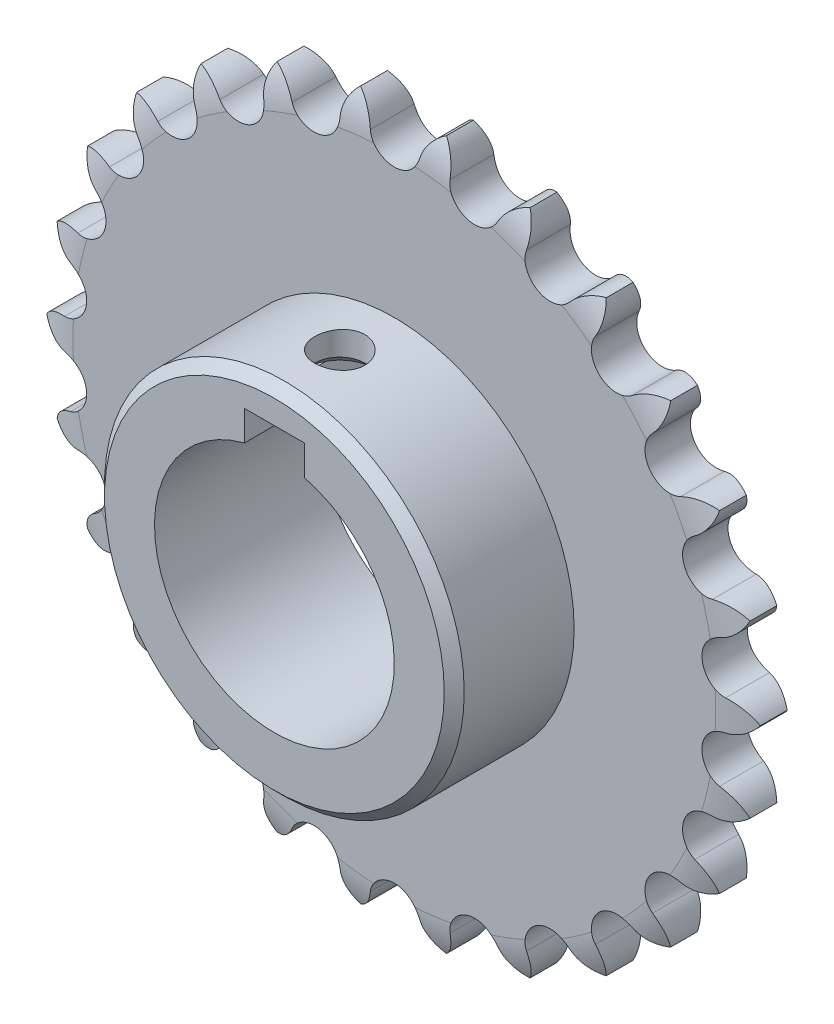
from build123d import *

# Parameters (mm, degrees)
SKETCH2_R           = 19.05
BOSS_EXTRUDE1_DEPTH = 7.2136
SKETCH3_W           = 19.05
SKETCH3_H           = 9.525
SKETCH4_W           = 9.525
SKETCH4_H           = 4.7625
CUT_EXTRUDE1_DEPTH  = 27.2636
CHAMFER1_SIZE       = 1.5875


with BuildPart() as part:
    # Sketch2 → Boss-Extrude1 (new body)
    with BuildSketch(Plane.XY):
        with BuildLine():
            ThreePointArc((3.92972164, 52.414466532), (0, 49.2633), (-3.92972164, 52.414466532))
            ThreePointArc((-3.92972164, 52.414466532), (-4.963717242, 54.655608441), (-6.832202969, 56.268253799))
            ThreePointArc((-6.832202969, 56.268253799), (-8.260462601, 54.255311081), (-8.728071805, 51.831841339))
            ThreePointArc((-8.728071805, 51.831841339), (-11.789479364, 47.831798034), (-16.359133948, 49.950953449))
            ThreePointArc((-16.359133948, 49.950953449), (-17.899423881, 51.879520503), (-20.099546104, 52.998147415))
            ThreePointArc((-20.099546104, 52.998147415), (-21.004574383, 50.701892252), (-20.878621442, 48.236937928))
            ThreePointArc((-20.878621442, 48.236937928), (-22.893797041, 43.620485829), (-27.837812853, 44.584472516))
            ThreePointArc((-27.837812853, 44.584472516), (-29.794881066, 46.088383408), (-32.198776678, 46.647981344))
            ThreePointArc((-32.198776678, 46.647981344), (-32.527976651, 44.201863738), (-31.815781492, 41.838679019))
            ThreePointArc((-31.815781492, 41.838679019), (-32.66761045, 36.87410954), (-37.698659262, 36.626904099))
            ThreePointArc((-37.698659262, 36.626904099), (-39.958768064, 37.618756994), (-42.426731389, 37.586804155))
            ThreePointArc((-42.426731389, 37.586804155), (-42.16097115, 35.132983572), (-40.903923967, 33.008908163))
            ThreePointArc((-40.903923967, 33.008908163), (-40.542901081, 27.984744038), (-45.368596624, 26.540713148))
            ThreePointArc((-45.368596624, 26.540713148), (-47.800396706, 26.962865161), (-50.188998688, 26.341218532))
            ThreePointArc((-50.188998688, 26.341218532), (-49.343723254, 24.022302103), (-47.614879061, 22.260779547))
            ThreePointArc((-47.614879061, 22.260779547), (-46.061985668, 17.469006932), (-50.401876058, 14.912072421))
            ThreePointArc((-50.401876058, 14.912072421), (-52.864040038, 14.739989612), (-55.034463811, 13.564777033))
            ThreePointArc((-55.034463811, 13.564777033), (-53.658797521, 11.515531754), (-51.558630457, 10.218935338))
            ThreePointArc((-51.558630457, 10.218935338), (-48.904115077, 5.93803464), (-52.505981658, 2.416796248))
            ThreePointArc((-52.505981658, 2.416796248), (-54.855417517, 1.660479444), (-56.681525941, 0))
            ThreePointArc((-56.681525941, 0), (-54.855417517, -1.660479444), (-52.505981658, -2.416796248))
            ThreePointArc((-52.505981658, -2.416796248), (-48.904115077, -5.93803464), (-51.558630457, -10.218935338))
            ThreePointArc((-51.558630457, -10.218935338), (-53.658797521, -11.515531754), (-55.034463811, -13.564777033))
            ThreePointArc((-55.034463811, -13.564777033), (-52.864040038, -14.739989612), (-50.401876058, -14.912072421))
            ThreePointArc((-50.401876058, -14.912072421), (-46.061985668, -17.469006932), (-47.614879061, -22.260779547))
            ThreePointArc((-47.614879061, -22.260779547), (-49.343723254, -24.022302103), (-50.188998688, -26.341218532))
            ThreePointArc((-50.188998688, -26.341218532), (-47.800396706, -26.962865161), (-45.368596624, -26.540713148))
            ThreePointArc((-45.368596624, -26.540713148), (-40.542901081, -27.984744038), (-40.903923967, -33.008908163))
            ThreePointArc((-40.903923967, -33.008908163), (-42.16097115, -35.132983572), (-42.426731389, -37.586804155))
            ThreePointArc((-42.426731389, -37.586804155), (-39.958768064, -37.618756994), (-37.698659262, -36.626904099))
            ThreePointArc((-37.698659262, -36.626904099), (-32.66761045, -36.87410954), (-31.815781492, -41.838679019))
            ThreePointArc((-31.815781492, -41.838679019), (-32.527976651, -44.201863738), (-32.198776678, -46.647981344))
            ThreePointArc((-32.198776678, -46.647981344), (-29.794881066, -46.088383408), (-27.837812853, -44.584472516))
            ThreePointArc((-27.837812853, -44.584472516), (-22.893797041, -43.620485829), (-20.878621442, -48.236937928))
            ThreePointArc((-20.878621442, -48.236937928), (-21.004574383, -50.701892252), (-20.099546104, -52.998147415))
            ThreePointArc((-20.099546104, -52.998147415), (-17.899423881, -51.879520503), (-16.359133948, -49.950953449))
            ThreePointArc((-16.359133948, -49.950953449), (-11.789479364, -47.831798034), (-8.728071805, -51.831841339))
            ThreePointArc((-8.728071805, -51.831841339), (-8.260462601, -54.255311081), (-6.832202969, -56.268253799))
            ThreePointArc((-6.832202969, -56.268253799), (-4.963717242, -54.655608441), (-3.92972164, -52.414466532))
            ThreePointArc((-3.92972164, -52.414466532), (0, -49.2633), (3.92972164, -52.414466532))
            ThreePointArc((3.92972164, -52.414466532), (4.963717242, -54.655608441), (6.832202969, -56.268253799))
            ThreePointArc((6.832202969, -56.268253799), (8.260462601, -54.255311081), (8.728071805, -51.831841339))
            ThreePointArc((8.728071805, -51.831841339), (11.789479364, -47.831798034), (16.359133948, -49.950953449))
            ThreePointArc((16.359133948, -49.950953449), (17.899423881, -51.879520503), (20.099546104, -52.998147415))
            ThreePointArc((20.099546104, -52.998147415), (21.004574383, -50.701892252), (20.878621442, -48.236937928))
            ThreePointArc((20.878621442, -48.236937928), (22.893797041, -43.620485829), (27.837812853, -44.584472516))
            ThreePointArc((27.837812853, -44.584472516), (29.794881066, -46.088383408), (32.198776678, -46.647981344))
            ThreePointArc((32.198776678, -46.647981344), (32.527976651, -44.201863738), (31.815781492, -41.838679019))
            ThreePointArc((31.815781492, -41.838679019), (32.66761045, -36.87410954), (37.698659262, -36.626904099))
            ThreePointArc((37.698659262, -36.626904099), (39.958768064, -37.618756994), (42.426731389, -37.586804155))
            ThreePointArc((42.426731389, -37.586804155), (42.16097115, -35.132983572), (40.903923967, -33.008908163))
            ThreePointArc((40.903923967, -33.008908163), (40.542901081, -27.984744038), (45.368596624, -26.540713148))
            ThreePointArc((45.368596624, -26.540713148), (47.800396706, -26.962865161), (50.188998688, -26.341218532))
            ThreePointArc((50.188998688, -26.341218532), (49.343723254, -24.022302103), (47.614879061, -22.260779547))
            ThreePointArc((47.614879061, -22.260779547), (46.061985668, -17.469006932), (50.401876058, -14.912072421))
            ThreePointArc((50.401876058, -14.912072421), (52.864040038, -14.739989612), (55.034463811, -13.564777033))
            ThreePointArc((55.034463811, -13.564777033), (53.658797521, -11.515531754), (51.558630457, -10.218935338))
            ThreePointArc((51.558630457, -10.218935338), (48.904115077, -5.93803464), (52.505981658, -2.416796248))
            ThreePointArc((52.505981658, -2.416796248), (54.855417517, -1.660479444), (56.681525941, 0))
            ThreePointArc((56.681525941, 0), (54.855417517, 1.660479444), (52.505981658, 2.416796248))
            ThreePointArc((52.505981658, 2.416796248), (48.904115077, 5.93803464), (51.558630457, 10.218935338))
            ThreePointArc((51.558630457, 10.218935338), (53.658797521, 11.515531754), (55.034463811, 13.564777033))
            ThreePointArc((55.034463811, 13.564777033), (52.864040038, 14.739989612), (50.401876058, 14.912072421))
            ThreePointArc((50.401876058, 14.912072421), (46.061985668, 17.469006932), (47.614879061, 22.260779547))
            ThreePointArc((47.614879061, 22.260779547), (49.343723254, 24.022302103), (50.188998688, 26.341218532))
            ThreePointArc((50.188998688, 26.341218532), (47.800396706, 26.962865161), (45.368596624, 26.540713148))
            ThreePointArc((45.368596624, 26.540713148), (40.542901081, 27.984744038), (40.903923967, 33.008908163))
            ThreePointArc((40.903923967, 33.008908163), (42.16097115, 35.132983572), (42.426731389, 37.586804155))
            ThreePointArc((42.426731389, 37.586804155), (39.958768064, 37.618756994), (37.698659262, 36.626904099))
            ThreePointArc((37.698659262, 36.626904099), (32.66761045, 36.87410954), (31.815781492, 41.838679019))
            ThreePointArc((31.815781492, 41.838679019), (32.527976651, 44.201863738), (32.198776678, 46.647981344))
            ThreePointArc((32.198776678, 46.647981344), (29.794881066, 46.088383408), (27.837812853, 44.584472516))
            ThreePointArc((27.837812853, 44.584472516), (22.893797041, 43.620485829), (20.878621442, 48.236937928))
            ThreePointArc((20.878621442, 48.236937928), (21.004574383, 50.701892252), (20.099546104, 52.998147415))
            ThreePointArc((20.099546104, 52.998147415), (17.899423881, 51.879520503), (16.359133948, 49.950953449))
            ThreePointArc((16.359133948, 49.950953449), (11.789479364, 47.831798034), (8.728071805, 51.831841339))
            ThreePointArc((8.728071805, 51.831841339), (8.260462601, 54.255311081), (6.832202969, 56.268253799))
            ThreePointArc((6.832202969, 56.268253799), (4.963717242, 54.655608441), (3.92972164, 52.414466532))
        make_face()
        Circle(SKETCH2_R, mode=Mode.SUBTRACT)
    extrude(amount=BOSS_EXTRUDE1_DEPTH)

    # Sketch3 → Revolve1 (revolve)
    with BuildSketch(Plane(origin=(0, 0, 0), x_dir=(0, 0, -1), z_dir=(1, 0, 0))):
        with Locations((-16.7386, 23.8125)):
            Rectangle(SKETCH3_W, SKETCH3_H)
    revolve(axis=Axis((0, 0, 0), (0, 0, 1)))

    # Sketch4 → Cut-Extrude1 (cut, through all)
    with BuildSketch(Plane.XY.offset(26.2636)):
        with Locations((0, 20.826333186)):
            Rectangle(SKETCH4_W, SKETCH4_H)
    extrude(amount=-CUT_EXTRUDE1_DEPTH, mode=Mode.SUBTRACT)

    # Sketch11 → 3/8-16 Tapped Hole2 (revolve, cut)
    with BuildSketch(Plane(origin=(0, 23.207583186, 15.875), x_dir=(0, 0, -1), z_dir=(1, 0, 0))):
        Polygon((0, 0), (0, 9.496665582), (3.96875, 7.112), (3.96875, 1.42875), (5.3975, 0), align=None)
    revolve(axis=Axis((0, 16.857583186, 15.875), (0, 1, 0)), mode=Mode.SUBTRACT)

    # Sketch12 → Cut-Revolve1 (revolve, cut)
    with BuildSketch(Plane(origin=(0, 0, 0), x_dir=(0, 0, -1), z_dir=(1, 0, 0))):
        with BuildLine():
            Line((-7.2136, 50.419), (-7.9756, 50.419))
            Line((-7.9756, 50.419), (-7.9756, 56.896))
            Line((-7.9756, 56.896), (-5.6261, 56.896))
            ThreePointArc((-5.6261, 56.896), (-6.852570348, 53.763558909), (-7.2136, 50.419))
        make_face()
        with BuildLine():
            Line((0, 50.419), (0.762, 50.419))
            Line((0.762, 50.419), (0.762, 56.896))
            Line((0.762, 56.896), (-1.5875, 56.896))
            ThreePointArc((-1.5875, 56.896), (-0.361029652, 53.763558909), (0, 50.419))
        make_face()
    revolve(axis=Axis((0, 0, 0), (0, 0, 1)), mode=Mode.SUBTRACT)

    # Chamfer1
    chamfer1_edges = [part.edges().sort_by_distance(p)[0] for p in [
        (0, -28.575, 26.2636),
    ]]
    chamfer(chamfer1_edges, length=CHAMFER1_SIZE)


solid = part.part
